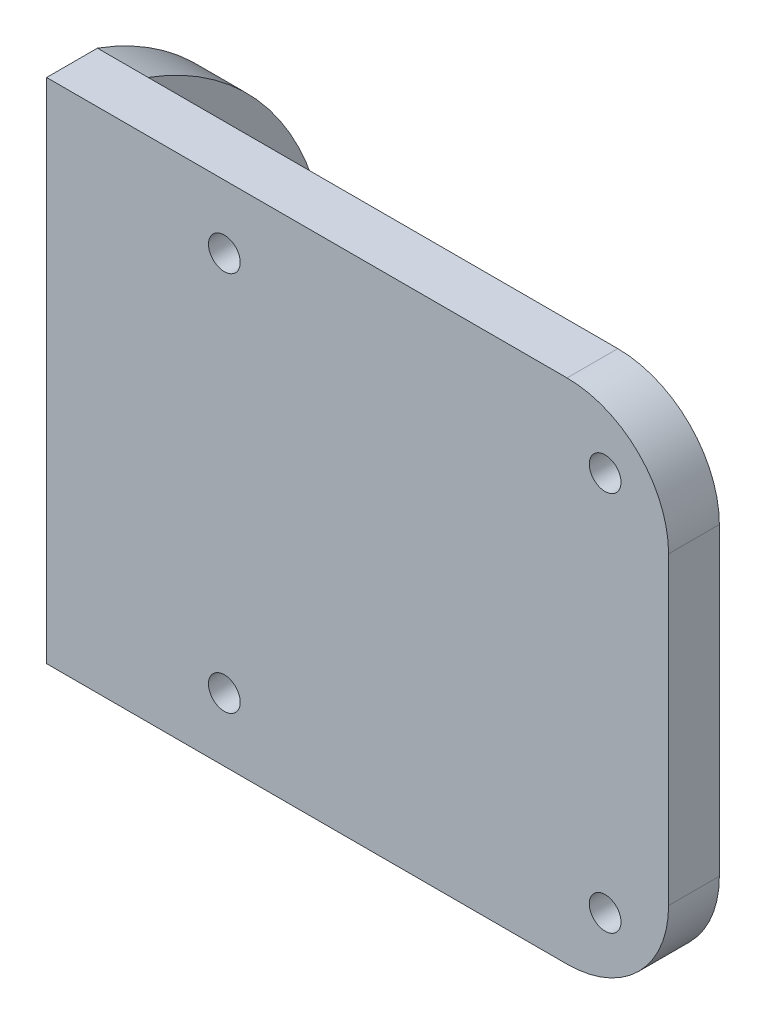
from build123d import *

# Parameters (mm, degrees)
SKETCH1_W           = 20
SKETCH1_H           = 20
BOSS_EXTRUDE1_DEPTH = 4
SKETCH2_R           = 1.1
CUT_EXTRUDE1_DEPTH  = 5
SKETCH3_W           = 4
SKETCH3_H           = 40
BOSS_EXTRUDE2_DEPTH = 45
SKETCH4_R           = 1.25
CUT_EXTRUDE2_DEPTH  = 10
SKETCH5_W           = 4
SKETCH5_H           = 10
BOSS_EXTRUDE4_DEPTH = 4
SKETCH6_W           = 16
SKETCH6_H           = 10
BOSS_EXTRUDE5_DEPTH = 4
CUT_EXTRUDE3_DEPTH  = 4
FILLET6_R           = 8


with BuildPart() as part:
    # Sketch1 → Boss-Extrude1 (new body)
    with BuildSketch(Plane(origin=(0, 0, 0), x_dir=(0, 0, -1), z_dir=(1, 0, 0))):
        Rectangle(SKETCH1_W, SKETCH1_H)
    extrude(amount=BOSS_EXTRUDE1_DEPTH)

    # Sketch2 → Cut-Extrude1 (cut, through all)
    with BuildSketch(Plane(origin=(4, 0, 0), x_dir=(0, 0, -1), z_dir=(1, 0, 0))):
        with Locations((-4.5, 0)):
            Circle(SKETCH2_R)
        with Locations((4.5, 0)):
            Circle(SKETCH2_R)
        with Locations((0, 4.5)):
            Circle(SKETCH2_R)
        with Locations((0, -4.5)):
            Circle(SKETCH2_R)
    extrude(amount=-CUT_EXTRUDE1_DEPTH, mode=Mode.SUBTRACT)

    # Sketch3 → Boss-Extrude2 (add)
    with BuildSketch(Plane(origin=(4, 0, 0), x_dir=(0, 0, -1), z_dir=(1, 0, 0))):
        with Locations((-8, 0)):
            Rectangle(SKETCH3_W, SKETCH3_H)
    extrude(amount=BOSS_EXTRUDE2_DEPTH)

    # Sketch4 → Cut-Extrude2 (cut)
    with BuildSketch(Plane.XY.offset(10)):
        with Locations((14, 15)):
            Circle(SKETCH4_R)
        with Locations((14, -15)):
            Circle(SKETCH4_R)
        with Locations((44, 15)):
            Circle(SKETCH4_R)
        with Locations((44, -15)):
            Circle(SKETCH4_R)
    extrude(amount=-CUT_EXTRUDE2_DEPTH, mode=Mode.SUBTRACT)

    # Sketch5 → Boss-Extrude4 (add)
    with BuildSketch(Plane.ZY.offset(-4)):
        with Locations((8, -15)):
            Rectangle(SKETCH5_W, SKETCH5_H)
        with Locations((8, 15)):
            Rectangle(SKETCH5_W, SKETCH5_H)
    extrude(amount=BOSS_EXTRUDE4_DEPTH)

    # Sketch6 → Boss-Extrude5 (add)
    with BuildSketch(Plane.ZY):
        with Locations((-2, 15)):
            Rectangle(SKETCH6_W, SKETCH6_H)
        with Locations((-2, -15)):
            Rectangle(SKETCH6_W, SKETCH6_H)
    extrude(amount=-BOSS_EXTRUDE5_DEPTH)

    # Sketch7 → Cut-Extrude3 (cut)
    with BuildSketch(Plane.ZY):
        with BuildLine():
            Line((-10, -20), (6, -20))
            ThreePointArc((6, -20), (-7.996256634, 0), (6, 20))
            Line((6, 20), (-10, 20))
            Line((-10, 20), (-10, -20))
        make_face()
    extrude(amount=-CUT_EXTRUDE3_DEPTH, mode=Mode.SUBTRACT)

    # Fillet6
    fillet6_edges = [part.edges().sort_by_distance(p)[0] for p in [
        (49, -20, 8),
        (49, 20, 8),
    ]]
    fillet(fillet6_edges, radius=FILLET6_R)


solid = part.part
